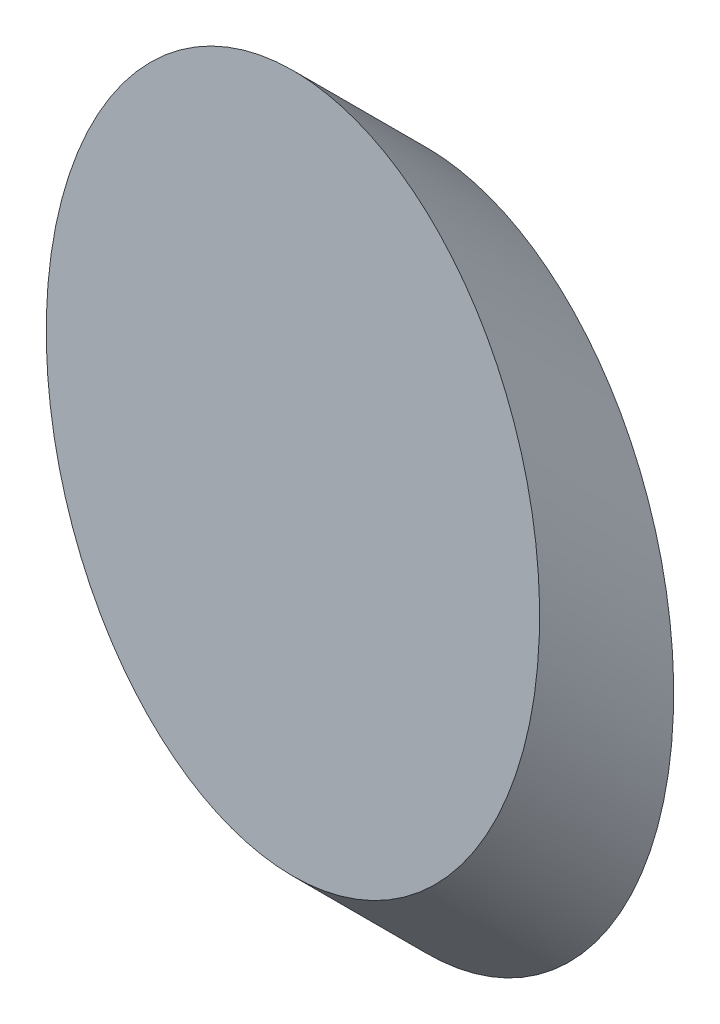
from build123d import *

# Parameters (mm, degrees)
SKETCH_1_RX     = 32.53
SKETCH_1_RY     = 23
EXTRUDE_2_DEPTH = 17.68


with BuildPart() as part:
    # 草图1 → 凸台-拉伸2 (new body, along a direction that is not the sketch's normal)
    with BuildSketch(Plane.XY):
        with Locations(Location((54.392382982, 35.78887153), (0, 0, 90))):
            Ellipse(SKETCH_1_RX, SKETCH_1_RY)
    extrude(amount=EXTRUDE_2_DEPTH, dir=(0, 0.707106781, 0.707106781))


solid = part.part
